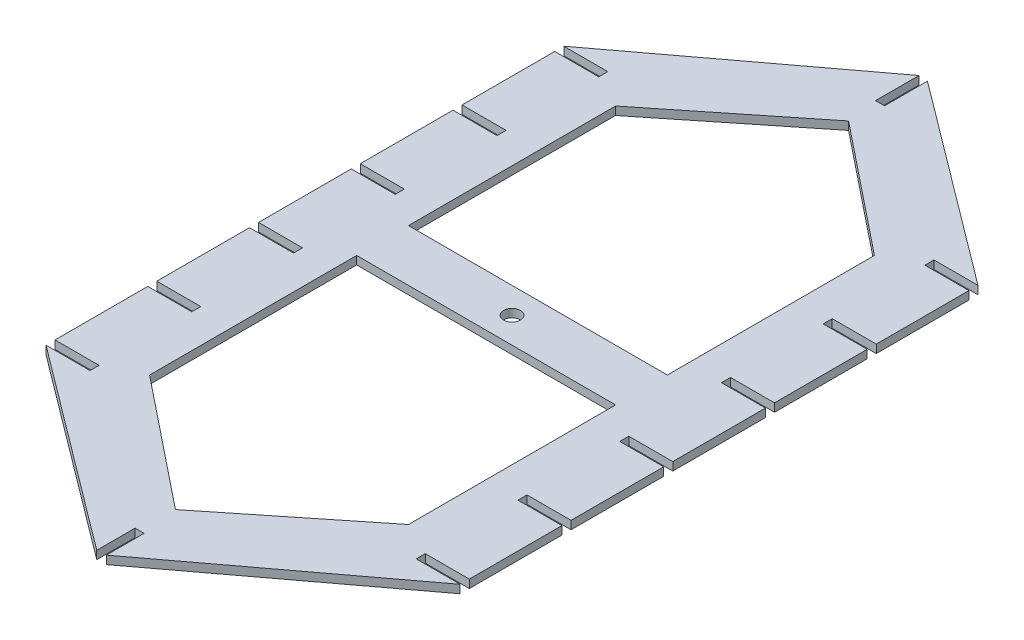
from build123d import *

# Parameters (mm, degrees)
BOSS_EXTRUDE1_DEPTH = 3.175
SKETCH3_R           = 3.25
SKETCH3_W           = 17
SKETCH3_H           = 3.5
CUT_EXTRUDE1_DEPTH  = 4.175
SKETCH4_W           = 3.5
SKETCH4_H           = 18
SKETCH4_H_2         = 16
CUT_EXTRUDE2_DEPTH  = 4.175


with BuildPart() as part:
    # Sketch2 → Boss-Extrude1 (new body)
    with BuildSketch(Plane(origin=(0, 0, 0), x_dir=(1, 0, 0), z_dir=(0, 1, 0))):
        Polygon((0, 200), (80, 260), (160, 200), (160, 0), (80, -60), (0, 0), align=None)
    extrude(amount=BOSS_EXTRUDE1_DEPTH)

    # Sketch3 → Cut-Extrude1 (cut, through all)
    with BuildSketch(Plane(origin=(0, 3.175, 0), x_dir=(1, 0, 0), z_dir=(0, 1, 0))):
        with Locations((80, 100)):
            Circle(SKETCH3_R)
        Polygon((30, 190), (80, 230), (130, 190), (130, 110), (30, 110), align=None)
        with Locations((8.5, 158.95)):
            Rectangle(SKETCH3_W, SKETCH3_H)
        Polygon((30, 90), (30, 10), (80, -30), (130, 10), (130, 90), align=None)
        with Locations((8.5, 198.25)):
            Rectangle(SKETCH3_W, SKETCH3_H)
        with Locations((8.5, 119.65)):
            Rectangle(SKETCH3_W, SKETCH3_H)
        with Locations((8.5, 80.35)):
            Rectangle(SKETCH3_W, SKETCH3_H)
        with Locations((8.5, 41.05)):
            Rectangle(SKETCH3_W, SKETCH3_H)
        with Locations((8.5, 1.75)):
            Rectangle(SKETCH3_W, SKETCH3_H)
        with Locations((151.5, 1.75)):
            Rectangle(SKETCH3_W, SKETCH3_H)
        with Locations((151.5, 41.05)):
            Rectangle(SKETCH3_W, SKETCH3_H)
        with Locations((151.5, 80.35)):
            Rectangle(SKETCH3_W, SKETCH3_H)
        with Locations((151.5, 119.65)):
            Rectangle(SKETCH3_W, SKETCH3_H)
        with Locations((151.5, 158.95)):
            Rectangle(SKETCH3_W, SKETCH3_H)
        with Locations((151.5, 198.25)):
            Rectangle(SKETCH3_W, SKETCH3_H)
    extrude(amount=-CUT_EXTRUDE1_DEPTH, mode=Mode.SUBTRACT)

    # Sketch4 → Cut-Extrude2 (cut, through all)
    with BuildSketch(Plane(origin=(0, 3.175, 0), x_dir=(1, 0, 0), z_dir=(0, 1, 0))):
        with Locations((80.16, 251)):
            Rectangle(SKETCH4_W, SKETCH4_H)
        with Locations((80.16, -52)):
            Rectangle(SKETCH4_W, SKETCH4_H_2)
    extrude(amount=-CUT_EXTRUDE2_DEPTH, mode=Mode.SUBTRACT)


solid = part.part
